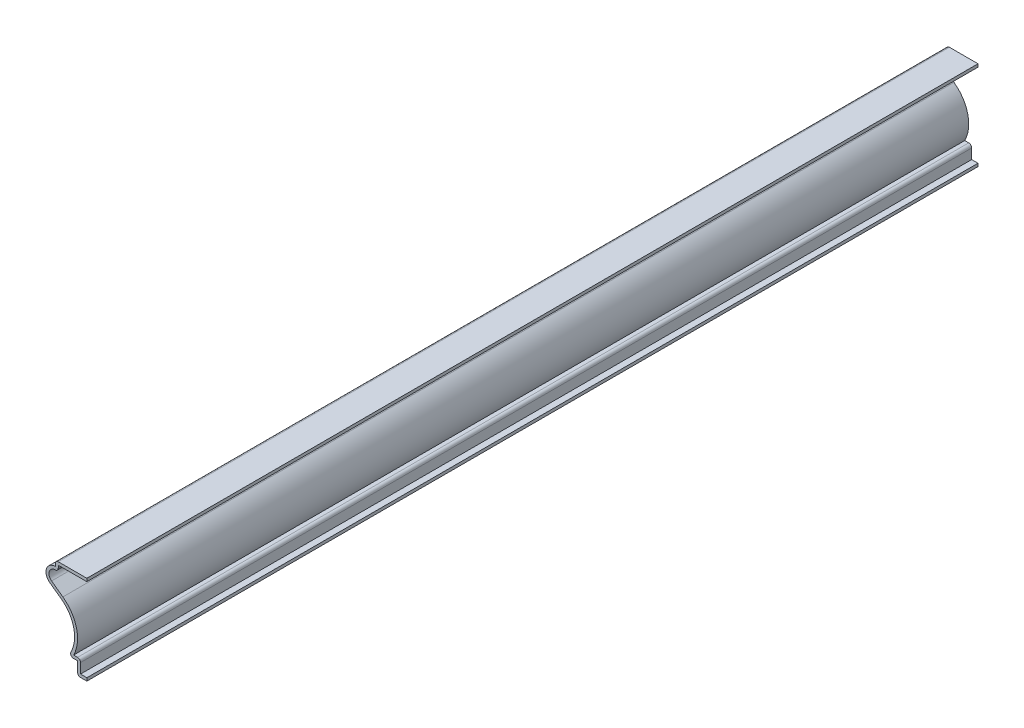
from build123d import *

# Parameters (mm, degrees)
EXTRUDE_THIN1_DEPTH = 381
FILLET1_R           = 1.27


with BuildPart() as part:
    # Sketch1 → Extrude-Thin1 (new body)
    with BuildSketch(Plane.XY):
        with BuildLine():
            Line((0, 0), (-3.96875, 0))
            Line((-3.96875, 0), (-3.96875, 5.55625))
            Line((-3.96875, 5.55625), (-7.9375, 5.55625))
            ThreePointArc((-7.9375, 5.55625), (-5.405853735, 15.931849892), (-10.986883491, 25.037585051))
            Line((-10.986883491, 25.037585051), (-15.820176145, 28.534612317))
            ThreePointArc((-15.820176145, 28.534612317), (-17.269464928, 32.972682848), (-13.49375, 35.71875))
            Line((-13.49375, 35.71875), (-13.49375, 38.1))
            Line((-13.49375, 38.1), (0, 38.1))
            Line((0, 38.1), (0, 36.83))
            Line((0, 36.83), (-12.22375, 36.83))
            Line((-12.22375, 36.83), (-12.22375, 34.13125))
            ThreePointArc((-12.22375, 34.13125), (-15.782927412, 33.179306943), (-15.075719779, 29.563536375))
            Line((-15.075719779, 29.563536375), (-10.242427125, 26.06650911))
            ThreePointArc((-10.242427125, 26.06650911), (-4.381358563, 17.296641703), (-5.659480864, 6.82625))
            Line((-5.659480864, 6.82625), (-2.69875, 6.82625))
            Line((-2.69875, 6.82625), (-2.69875, 1.27))
            Line((-2.69875, 1.27), (0, 1.27))
            Line((0, 1.27), (0, 0))
        make_face()
    extrude(amount=-EXTRUDE_THIN1_DEPTH)

    # Fillet1
    fillet1_edges = [part.edges().sort_by_distance(p)[0] for p in [
        (-3.96875, 0, -190.5),
        (-7.9375, 5.55625, -190.5),
        (-13.49375, 38.1, -190.5),
        (-12.22375, 34.13125, -190.5),
        (-2.69875, 6.82625, -190.5),
    ]]
    fillet(fillet1_edges, radius=FILLET1_R)


solid = part.part
